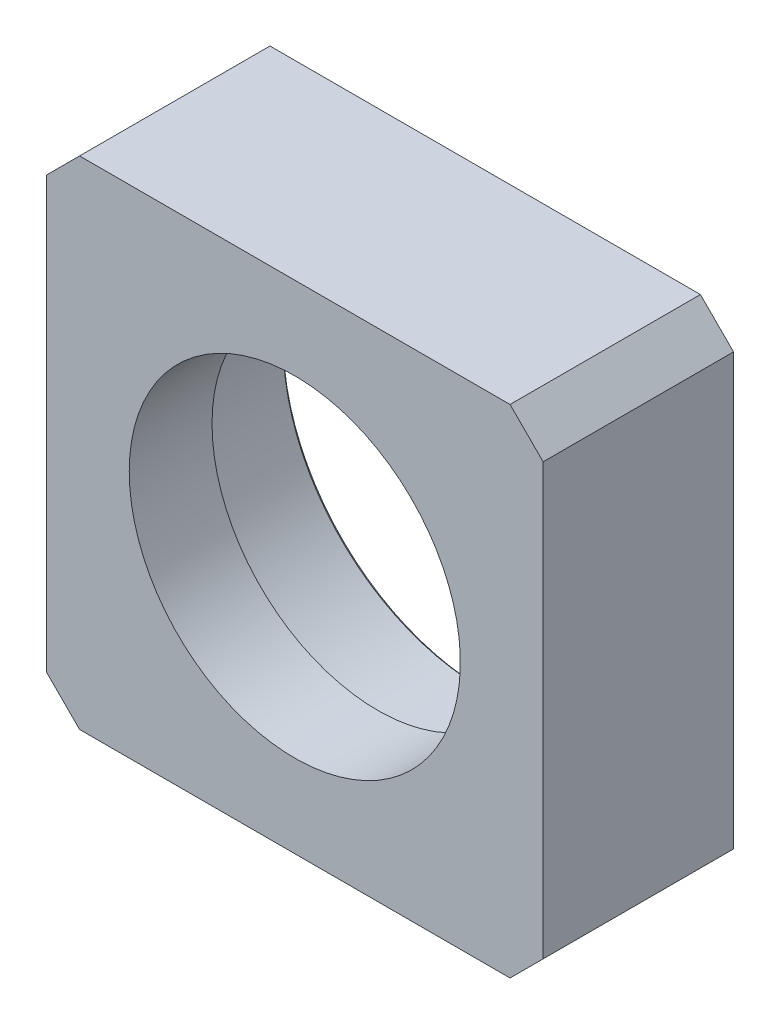
from build123d import *

# Parameters (mm, degrees)
SKETCH1_W           = 30
SKETCH1_H           = 30
BOSS_EXTRUDE1_DEPTH = 11.5
SKETCH2_R           = 12
CUT_EXTRUDE1_DEPTH  = 6.5
SKETCH3_R           = 10
CUT_EXTRUDE2_DEPTH  = 6
CHAMFER1_SIZE       = 2
CHAMFER_1_SIZE      = 0.2


with BuildPart() as part:
    # Sketch1 → Boss-Extrude1 (new body)
    with BuildSketch(Plane.XY):
        Rectangle(SKETCH1_W, SKETCH1_H)
    extrude(amount=BOSS_EXTRUDE1_DEPTH)

    # Sketch2 → Cut-Extrude1 (cut)
    with BuildSketch(Plane(origin=(0, 0, 0), x_dir=(-1, 0, 0), z_dir=(0, 0, -1))):
        Circle(SKETCH2_R)
    extrude(amount=-CUT_EXTRUDE1_DEPTH, mode=Mode.SUBTRACT)

    # Sketch3 → Cut-Extrude2 (cut, through all)
    with BuildSketch(Plane(origin=(0, 0, 6.5), x_dir=(-1, 0, 0), z_dir=(0, 0, -1))):
        Circle(SKETCH3_R)
    extrude(amount=-CUT_EXTRUDE2_DEPTH, mode=Mode.SUBTRACT)

    # Chamfer1
    chamfer1_edges = [part.edges().sort_by_distance(p)[0] for p in [
        (-15, -15, 5.75),
        (-15, 15, 5.75),
        (15, 15, 5.75),
        (15, -15, 5.75),
    ]]
    chamfer(chamfer1_edges, length=CHAMFER1_SIZE)

    # 倒角1
    chamfer_1_edges = [part.edges().sort_by_distance(p)[0] for p in [
        (12, 0, 0),
    ]]
    chamfer(chamfer_1_edges, length=CHAMFER_1_SIZE)


solid = part.part
